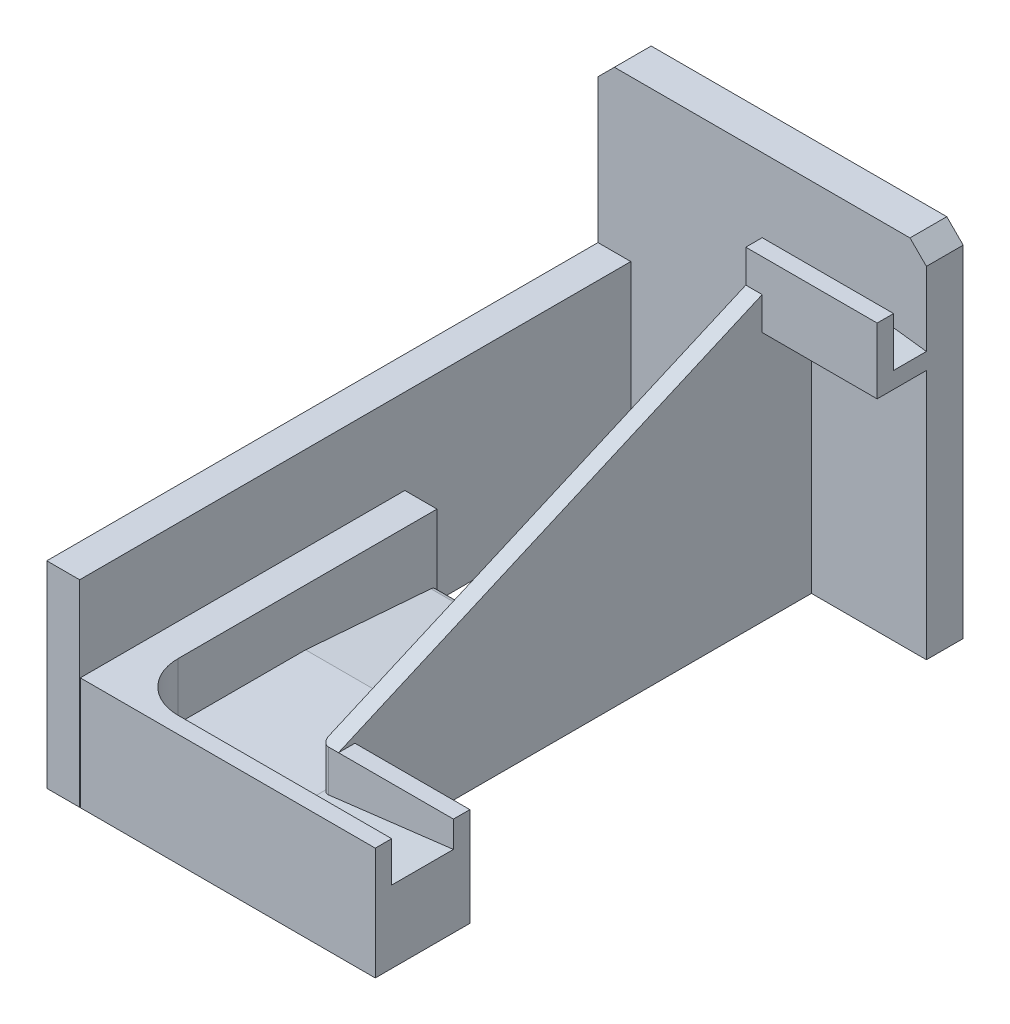
from build123d import *

# Parameters (mm, degrees)
EXTRUDE_1_DEPTH  = 11.2
SKETCH_3_W       = 40
SKETCH_3_H       = 20
EXTRUDE_2_DEPTH  = 5
EXTRUDE_3_DEPTH  = 10
EXTRUDE_4_DEPTH  = 5
SKETCH_7_W       = 98.8
SKETCH_7_H       = 34.24
EXTRUDE_5_DEPTH  = 9.8
SKETCH_8_W       = 80
SKETCH_8_H       = 34.24
EXTRUDE_6_DEPTH  = 5
SKETCH_9_W       = 35
SKETCH_9_H       = 30
EXTRUDE_7_DEPTH  = 5
EXTRUDE_8_DEPTH  = 40
FILLET_1_R       = 2
EXTRUDE_9_REACH  = 25.8
SKETCH_14_W      = 10
SKETCH_14_H      = 60
EXTRUDE_12_DEPTH = 167.8
EXTRUDE_13_DEPTH = 17.12
FILLET_3_R       = 2


with BuildPart() as part:
    # 草图1 → 凸台-拉伸1 (new body)
    with BuildSketch(Plane.XY):
        Polygon((0, 103.73), (5, 108.73), (95, 108.73), (100, 103.73), (100, 0), (0, 0), align=None)
    extrude(amount=EXTRUDE_1_DEPTH)



with BuildPart() as body_2:
    # 草图3 → 凸台-拉伸2 (new body)
    with BuildSketch(Plane.XY.offset(21.2)):
        with Locations((80, 86.29)):
            Rectangle(SKETCH_3_W, SKETCH_3_H)
    extrude(amount=EXTRUDE_2_DEPTH)


with BuildPart() as part_1:
    add(part.part)

    add(body_2.part)  # 凸台-拉伸3 merges body 2
    # 草图5 → 凸台-拉伸3 (add)
    with BuildSketch(Plane(origin=(0, 0, 21.2), x_dir=(-1, 0, 0), z_dir=(0, 0, -1))):
        Polygon((-60, 86.29), (-100, 81.29), (-100, 76.29), (-60, 76.29), align=None)
    extrude(amount=EXTRUDE_3_DEPTH)

    # 草图6 → 凸台-拉伸4 (add)
    with BuildSketch(Plane.ZY.offset(-60)):
        Polygon((26.2, 86.29), (155.2, 30), (155.2, 0), (26.2, 0), (11.2, 0), (11.2, 76.29), (26.2, 76.29), align=None)
    extrude(amount=-EXTRUDE_4_DEPTH)

    # 草图9 → 凸台-拉伸7 (add)
    with BuildSketch(Plane.XY.offset(155.2)):
        with Locations((82.5, 15)):
            Rectangle(SKETCH_9_W, SKETCH_9_H)
    extrude(amount=-EXTRUDE_7_DEPTH)



with BuildPart() as body_2_2:
    # 草图7 → 凸台-拉伸5 (new body)
    with BuildSketch(Plane.ZY.offset(-10.2)):
        with Locations((129.6, 17.12)):
            Rectangle(SKETCH_7_W, SKETCH_7_H)
    extrude(amount=-EXTRUDE_5_DEPTH)

    # 草图8 → 凸台-拉伸6 (add)
    with BuildSketch(Plane.XY.offset(179)):
        with Locations((60, 17.12)):
            Rectangle(SKETCH_8_W, SKETCH_8_H)
    extrude(amount=-EXTRUDE_6_DEPTH)


with BuildPart() as part_2:
    add(part_1.part)

    add(body_2_2.part)  # 凸台-拉伸8 merges body 2 2
    # 草图11 → 凸台-拉伸8 (add)
    with BuildSketch(Plane(origin=(20, 0, 0), x_dir=(0, 0, -1), z_dir=(1, 0, 0))):
        Polygon((-80.2, 0), (-80.2, 14), (-120.2, 17.12), (-174, 17.12), (-174, 0), align=None)
    extrude(amount=EXTRUDE_8_DEPTH)

    # 圆角1
    fillet_1_edges = [part_2.edges().sort_by_distance(p)[0] for p in [
        (40, 14, 80.2),
    ]]
    fillet(fillet_1_edges, radius=FILLET_1_R)

    # 草图12 → 凸台-拉伸9 (add, up to next)
    with BuildSketch(Plane.XY.offset(155.2), mode=Mode.PRIVATE) as extrude_9_sk1:
        Polygon((60, 0), (60, 17.12), (100, 22), (100, 0), align=None)
    extrude_9_tool1 = extrude(extrude_9_sk1.sketch, amount=EXTRUDE_9_REACH, mode=Mode.PRIVATE) - part_2.part
    add(extrude_9_tool1.solids().sort_by_distance((80.831629, 9.830729, 155.2))[0])

    # 草图14 → 凸台-拉伸12 (add)
    with BuildSketch(Plane.XY.offset(11.2)):
        with Locations((5, 30)):
            Rectangle(SKETCH_14_W, SKETCH_14_H)
    extrude(amount=EXTRUDE_12_DEPTH)

    # 草图15 → 凸台-拉伸13 (add)
    with BuildSketch(Plane(origin=(0, 17.12, 0), x_dir=(1, 0, 0), z_dir=(0, 1, 0))):
        with BuildLine():
            Line((20, -159), (20, -174))
            Line((20, -174), (35, -174))
            ThreePointArc((35, -174), (24.393398282, -169.606601718), (20, -159))
        make_face()
    extrude(amount=EXTRUDE_13_DEPTH)

    # 圆角3
    fillet_3_edges = [part_2.edges().sort_by_distance(p)[0] for p in [
        (60, 23.56, 155.2),
    ]]
    fillet(fillet_3_edges, radius=FILLET_3_R)


solid = part_2.part
